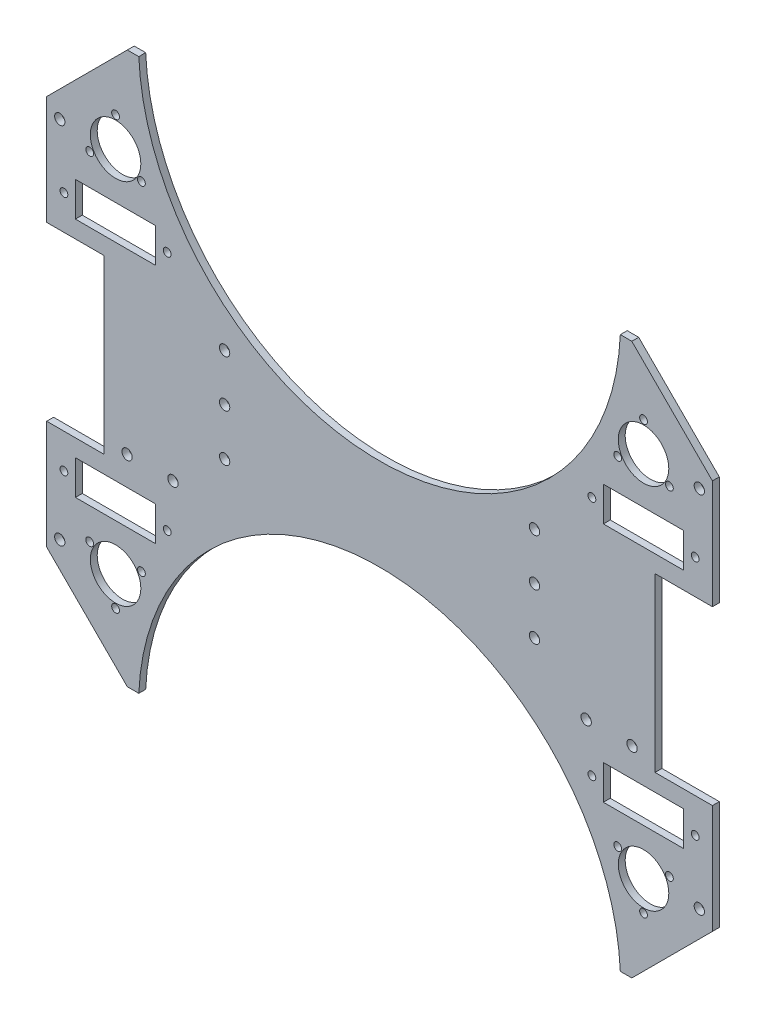
from build123d import *

# Parameters (mm, degrees)
BOSS_EXTRU_1_DEPTH      = 3
D_GAGEMENT_M41_D        = 4.5
D_GAGEMENT_M41_DEPTH    = 10
D_GAGEMENT_M41_TIP      = 1.351936393
D_GAGEMENT_M201_D       = 22
D_GAGEMENT_M201_DEPTH   = 10
D_GAGEMENT_M201_TIP     = 6.609466809
D_GAGEMENT_M32_D        = 3.4
D_GAGEMENT_M32_DEPTH    = 10
D_GAGEMENT_M32_TIP      = 1.021463052
D_GAGEMENT_M43_D        = 4.5
ESQUISSE27_W            = 35
ESQUISSE27_H            = 15
ENL_V_MAT_EXTRU_2_DEPTH = 4
D_GAGEMENT_M33_D        = 3.4
D_GAGEMENT_M33_DEPTH    = 7.01
D_GAGEMENT_M33_TIP      = 1.021463052


with BuildPart() as part:
    # Esquisse1 → Boss.-Extru.1 (new body)
    with BuildSketch(Plane.XY):
        with BuildLine():
            Line((-145, 85), (-109.886246, 120.113754))
            Line((-109.886246, 120.113754), (-104.886246, 120.113754))
            ThreePointArc((-104.886246, 120.113754), (0, 20), (104.886246, 120.113754))
            Line((104.886246, 120.113754), (109.886246, 120.113754))
            Line((109.886246, 120.113754), (145, 85))
            Line((145, 85), (145, 37.5))
            Line((145, 37.5), (120, 37.5))
            Line((120, 37.5), (120, -37.5))
            Line((120, -37.5), (145, -37.5))
            Line((145, -37.5), (145, -85))
            Line((145, -85), (109.886246, -120.113754))
            Line((109.886246, -120.113754), (104.886246, -120.113754))
            ThreePointArc((104.886246, -120.113754), (0, -20), (-104.886246, -120.113754))
            Line((-104.886246, -120.113754), (-109.886246, -120.113754))
            Line((-109.886246, -120.113754), (-145, -85))
            Line((-145, -85), (-145, -37.5))
            Line((-145, -37.5), (-120, -37.5))
            Line((-120, -37.5), (-120, 37.5))
            Line((-120, 37.5), (-145, 37.5))
            Line((-145, 37.5), (-145, 85))
        make_face()
    extrude(amount=BOSS_EXTRU_1_DEPTH)

    # Dégagement M41
    with Locations(Plane(origin=(-139.3, 79.3, 3), x_dir=(1, 0, 0), z_dir=(0, 0, 1))):
        with Locations((0, 0), (278.6, 0), (278.6, -158.6), (0, -158.6)):
            Hole(D_GAGEMENT_M41_D / 2, depth=D_GAGEMENT_M41_DEPTH)
            with Locations((0, 0, -(D_GAGEMENT_M41_DEPTH + D_GAGEMENT_M41_TIP / 2))):  # 118° drill point
                Cone(0, D_GAGEMENT_M41_D / 2, D_GAGEMENT_M41_TIP, mode=Mode.SUBTRACT)

    # Dégagement M201
    with Locations(Plane(origin=(-115, 80.113754, 3), x_dir=(1, 0, 0), z_dir=(0, 0, 1))):
        with Locations((0, 0), (230, 0), (230, -160.227508), (0, -160.227508)):
            Hole(D_GAGEMENT_M201_D / 2, depth=D_GAGEMENT_M201_DEPTH)
            with Locations((0, 0, -(D_GAGEMENT_M201_DEPTH + D_GAGEMENT_M201_TIP / 2))):  # 118° drill point
                Cone(0, D_GAGEMENT_M201_D / 2, D_GAGEMENT_M201_TIP, mode=Mode.SUBTRACT)

    # Dégagement M32
    with Locations(Plane.XY.offset(3)):
        with Locations((-103.741669751, 73.613754), (-115, 93.113754), (-126.258330249, 73.613754), (-103.741669751, -73.613754), (-126.258330249, -73.613754), (-115, -93.113754), (115, -93.113754), (126.258330249, -73.613754), (103.741669751, -73.613754), (103.741669751, 73.613754), (115, 93.113754), (126.258330249, 73.613754)):
            Hole(D_GAGEMENT_M32_D / 2, depth=D_GAGEMENT_M32_DEPTH)
            with Locations((0, 0, -(D_GAGEMENT_M32_DEPTH + D_GAGEMENT_M32_TIP / 2))):  # 118° drill point
                Cone(0, D_GAGEMENT_M32_D / 2, D_GAGEMENT_M32_TIP, mode=Mode.SUBTRACT)

    # Dégagement M43 (through all)
    with Locations(Plane.XY.offset(3)):
        with Locations((-110, -32.5), (-90, -32.5), (-67.5, -13), (-67.5, 7.5), (-67.5, 28), (67.5, 28), (67.5, 7.5), (67.5, -13), (90, -32.5), (110, -32.5)):
            Hole(D_GAGEMENT_M43_D / 2)

    # Esquisse27 → Enlèv. mat.-Extru.2 (cut, through all)
    with BuildSketch(Plane(origin=(0, 0, 0), x_dir=(-1, 0, 0), z_dir=(0, 0, -1))):
        with Locations((-115, 52.5)):
            Rectangle(ESQUISSE27_W, ESQUISSE27_H)
        with Locations((-115, -52.5)):
            Rectangle(ESQUISSE27_W, ESQUISSE27_H)
        with Locations((115, -52.5)):
            Rectangle(ESQUISSE27_W, ESQUISSE27_H)
        with Locations((115, 52.5)):
            Rectangle(ESQUISSE27_W, ESQUISSE27_H)
    extrude(amount=-ENL_V_MAT_EXTRU_2_DEPTH, mode=Mode.SUBTRACT)

    # Dégagement M33
    with Locations(Plane(origin=(0, 0, 0), x_dir=(-1, 0, 0), z_dir=(0, 0, -1))):
        with Locations((-137.5, 52.5), (-92.5, 52.5), (-137.5, -52.5), (-92.5, -52.5), (92.5, 52.5), (137.5, 52.5), (92.5, -52.5), (137.5, -52.5)):
            Hole(D_GAGEMENT_M33_D / 2, depth=D_GAGEMENT_M33_DEPTH)
            with Locations((0, 0, -(D_GAGEMENT_M33_DEPTH + D_GAGEMENT_M33_TIP / 2))):  # 118° drill point
                Cone(0, D_GAGEMENT_M33_D / 2, D_GAGEMENT_M33_TIP, mode=Mode.SUBTRACT)


solid = part.part
